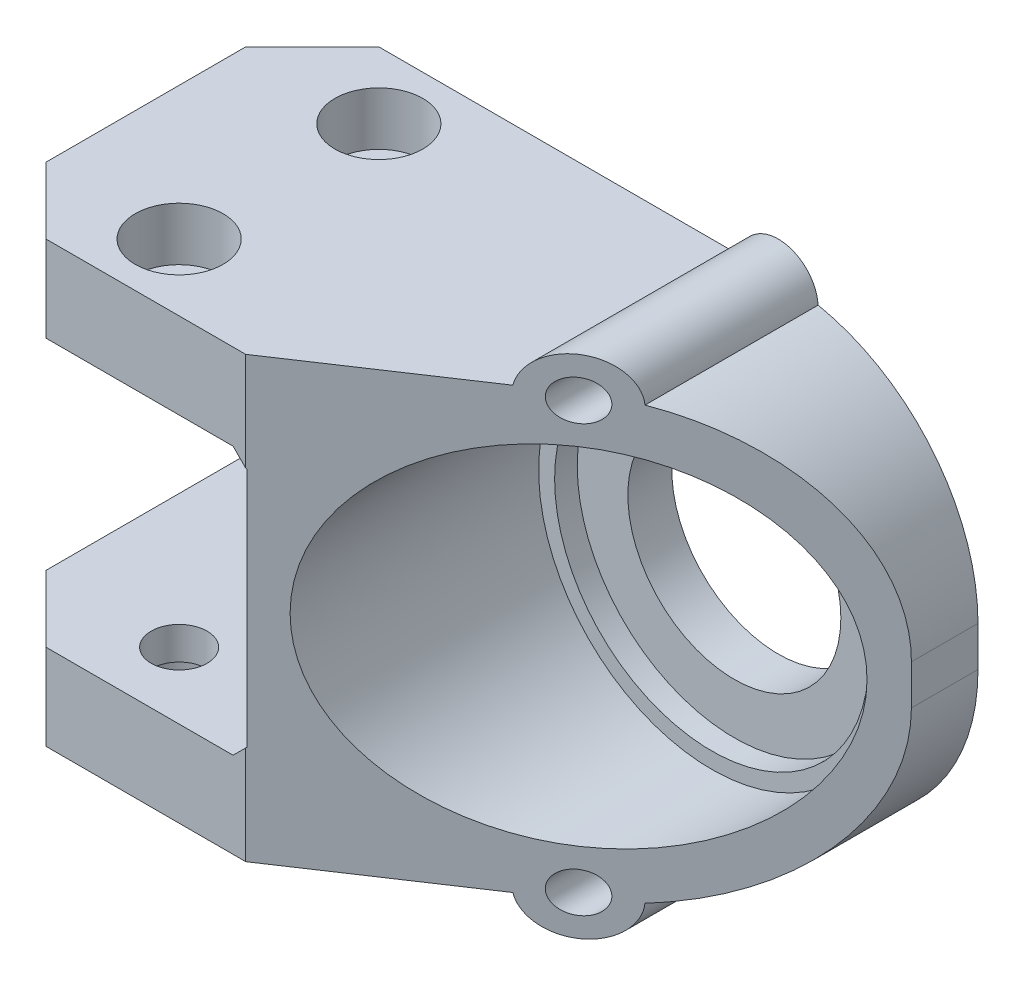
from build123d import *

# Parameters (mm, degrees)
SKETCH1_R           = 4.2
BOSS_EXTRUDE1_DEPTH = 33
SKETCH2_R           = 16
SKETCH2_W           = 40.2
SKETCH2_H           = 40.2
CUT_EXTRUDE1_DEPTH  = 117.571866246
CUT_EXTRUDE2_START  = 10
SKETCH3_R           = 26
CUT_EXTRUDE2_DEPTH  = 107.571866246
SKETCH4_R           = 23.6
CUT_EXTRUDE3_DEPTH  = 3.4
FILLET1_R           = 30
CHAMFER1_SIZE       = 2
CUT_EXTRUDE5_START  = -25
SKETCH5_R           = 6.6
CUT_EXTRUDE5_DEPTH  = 92.571866246
CHAMFER2_SIZE       = 10
BOSS_EXTRUDE2_REACH = 118.572
SKETCH6_R           = 3
SKETCH6_2_R         = 3
CUT_EXTRUDE6_DEPTH  = 119.084715353


with BuildPart() as part:
    # Sketch1 → Boss-Extrude1 (new, symmetric)
    with BuildSketch(Plane(origin=(0, 0, 0), x_dir=(1, 0, 0), z_dir=(0, 1, 0))):
        Polygon((0, 0), (0, -50), (40, -50), (100, -10), (100, 0), align=None)
        with Locations(Location((20, -10, 0), (0, 0, 270))):
            Circle(SKETCH1_R, mode=Mode.SUBTRACT)
        with Locations(Location((20, -40, 0), (0, 0, 270))):
            Circle(SKETCH1_R, mode=Mode.SUBTRACT)
    extrude(amount=BOSS_EXTRUDE1_DEPTH, both=True)

    # Sketch2 → Cut-Extrude1 (cut, through all)
    with BuildSketch(Plane.XY):
        with Locations((70, 0)):
            Circle(SKETCH2_R)
        with Locations((20, 0)):
            Rectangle(SKETCH2_W, SKETCH2_H)
    extrude(amount=CUT_EXTRUDE1_DEPTH, mode=Mode.SUBTRACT)

    # Sketch3 → Cut-Extrude2 (cut, through all)
    with BuildSketch(Plane.XY.offset(CUT_EXTRUDE2_START)):
        with Locations((70, 0)):
            Circle(SKETCH3_R)
    extrude(amount=CUT_EXTRUDE2_DEPTH, mode=Mode.SUBTRACT)

    # Sketch4 → Cut-Extrude3 (cut)
    with BuildSketch(Plane.XY.offset(10)):
        with Locations((70, 0)):
            Circle(SKETCH4_R)
    extrude(amount=-CUT_EXTRUDE3_DEPTH, mode=Mode.SUBTRACT)

    # Fillet1
    fillet1_edges = [part.edges().sort_by_distance(p)[0] for p in [
        (100, 33, 5),
        (100, -33, 5),
    ]]
    fillet(fillet1_edges, radius=FILLET1_R)

    # Chamfer1
    chamfer1_edges = [part.edges().sort_by_distance(p)[0] for p in [
        (40.1, -20.1, 24.966666667),
        (40.1, 20.1, 24.966666667),
    ]]
    chamfer(chamfer1_edges, length=CHAMFER1_SIZE)

    # Sketch5 → Cut-Extrude5 (cut, through all)
    with BuildSketch(Plane(origin=(0, 0, 0), x_dir=(1, 0, 0), z_dir=(0, 1, 0)).offset(CUT_EXTRUDE5_START)):
        with Locations(Location((20, -40, 0), (0, 0, 270))):
            Circle(SKETCH5_R)
        with Locations(Location((20, -10, 0), (0, 0, 270))):
            Circle(SKETCH5_R)
    cut_extrude5 = extrude(amount=-CUT_EXTRUDE5_DEPTH, mode=Mode.SUBTRACT)

    # Mirror1: Cut-Extrude5 across plane
    add(cut_extrude5.mirror(Plane.ZX), mode=Mode.SUBTRACT)

    # Chamfer2
    chamfer2_edges = [part.edges().sort_by_distance(p)[0] for p in [
        (0, -26.55, 50),
        (0, -26.55, 0),
        (0, 26.55, 50),
        (0, 26.55, 0),
    ]]
    chamfer(chamfer2_edges, length=CHAMFER2_SIZE)

    # Boss-Extrude2: up to this plane
    boss_extrude2_end = Plane(origin=(40, 33, 50), z_dir=(-0.5547001962252289, 0, -0.8320502943378438))
    # Sketch6 → Boss-Extrude2 (add, up to the surface)
    with BuildSketch(Plane.XY, mode=Mode.PRIVATE) as boss_extrude2_sk1:
        with BuildLine():
            Line((66.68337521, 27), (73.31662479, 27))
            ThreePointArc((73.31662479, 27), (70, 38), (66.68337521, 27))
        make_face()
        with Locations((70, 32)):
            Circle(SKETCH6_R, mode=Mode.SUBTRACT)
    boss_extrude2_tool1 = split(extrude(boss_extrude2_sk1.sketch, amount=BOSS_EXTRUDE2_REACH, mode=Mode.PRIVATE), bisect_by=boss_extrude2_end, keep=Keep.BOTH, mode=Mode.PRIVATE)
    boss_extrude2 = boss_extrude2_tool1.solids().sort_by_distance((70, 27.162788, 0))[0]
    add(boss_extrude2)

    # Sketch6_2 → Cut-Extrude6 (cut, through all)
    with BuildSketch(Plane.XY):
        with Locations((70, 32)):
            Circle(SKETCH6_2_R)
    cut_extrude6 = extrude(amount=CUT_EXTRUDE6_DEPTH, mode=Mode.SUBTRACT)

    # Mirror2: Boss-Extrude2, Cut-Extrude6 across plane
    add(boss_extrude2.mirror(Plane.ZX))
    add(cut_extrude6.mirror(Plane.ZX), mode=Mode.SUBTRACT)


solid = part.part
